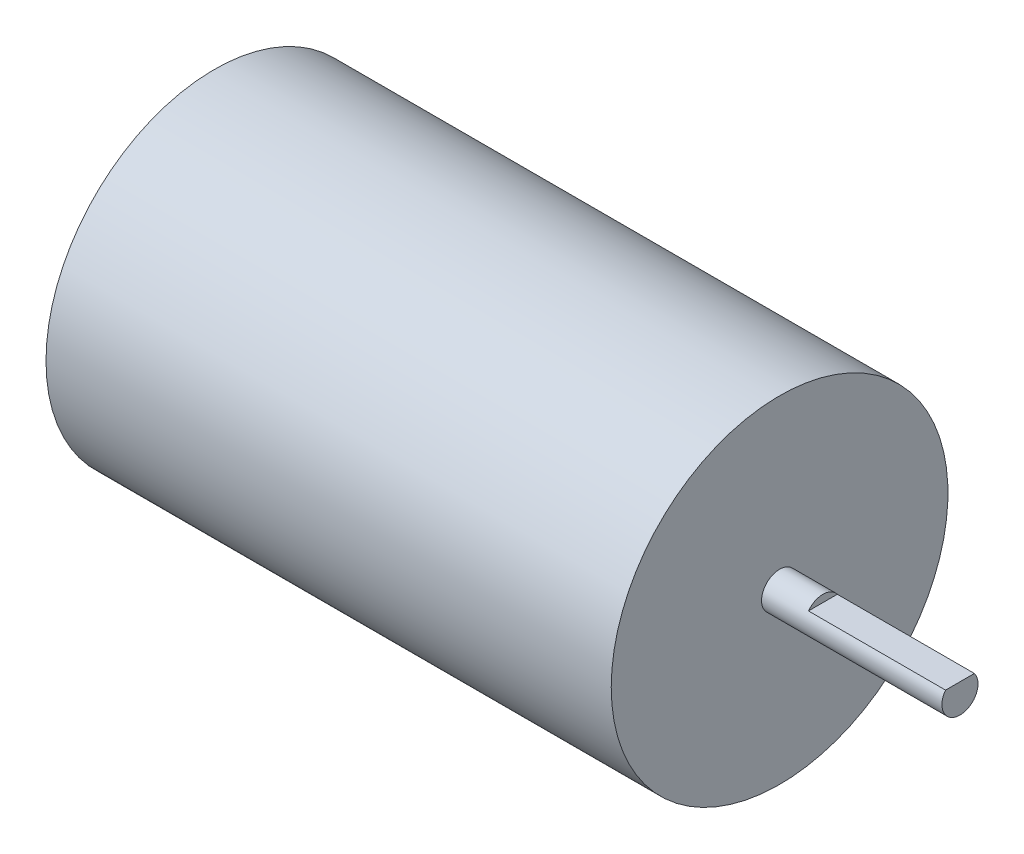
from build123d import *

# Parameters (mm, degrees)
SKETCH1_W           = 47
SKETCH1_H           = 14
SKETCH2_R           = 1.5
BOSS_EXTRUDE1_DEPTH = 15
CUT_EXTRUDE1_DEPTH  = 11.4


with BuildPart() as part:
    # Sketch1 → Revolve1 (revolve)
    with BuildSketch(Plane.XY):
        with Locations((23.5, 7)):
            Rectangle(SKETCH1_W, SKETCH1_H)
    revolve(axis=Axis((0, 0, 0), (1, 0, 0)))

    # Sketch2 → Boss-Extrude1 (add)
    with BuildSketch(Plane(origin=(47, 0, 0), x_dir=(0, 0, -1), z_dir=(1, 0, 0))):
        Circle(SKETCH2_R)
    extrude(amount=BOSS_EXTRUDE1_DEPTH)

    # Sketch3 → Cut-Extrude1 (cut)
    with BuildSketch(Plane(origin=(62, 0, 0), x_dir=(0, 0, -1), z_dir=(1, 0, 0))):
        with BuildLine():
            Line((-1.2, 0.9), (1.2, 0.9))
            ThreePointArc((1.2, 0.9), (0, 1.5), (-1.2, 0.9))
        make_face()
    extrude(amount=-CUT_EXTRUDE1_DEPTH, mode=Mode.SUBTRACT)


solid = part.part
